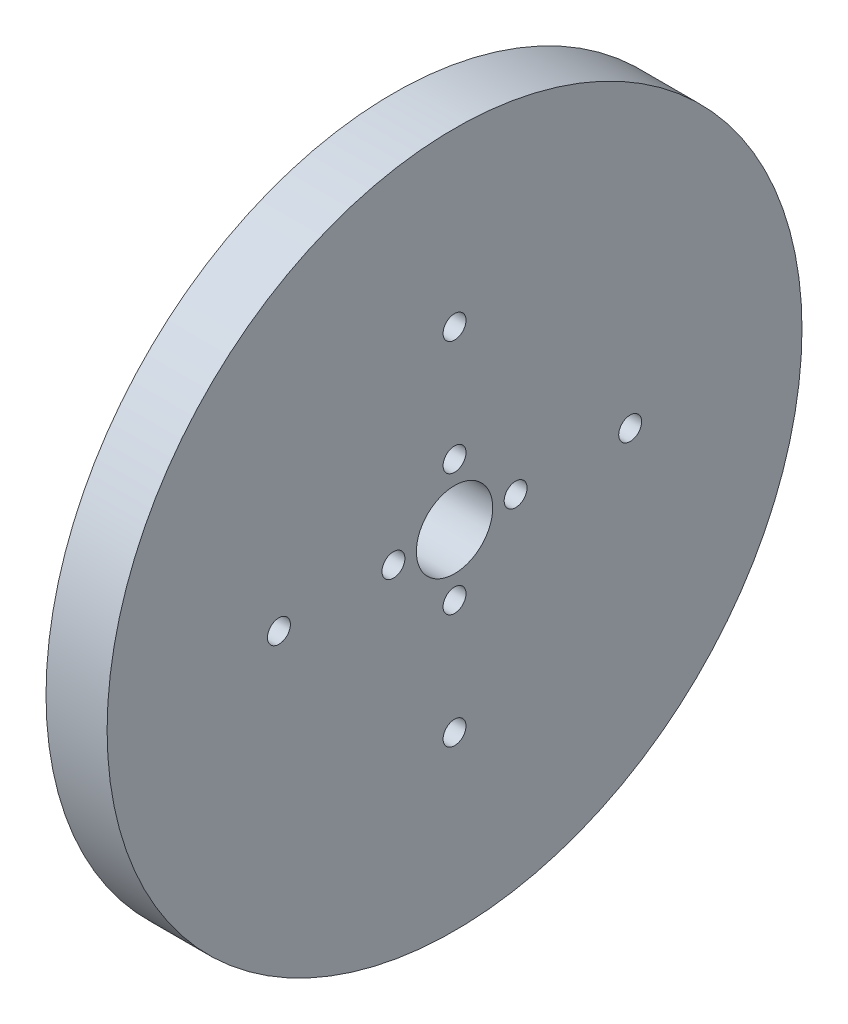
from build123d import *

# Parameters (mm, degrees)
SPROCKET_R                   = 45.5
ESTRUSIONE_ESTRUSIONE2_DEPTH = 8
SCHIZZO1_R                   = 5
SCHIZZO1_R_2                 = 1.5
TAGLIO_ESTRUSIONE2_DEPTH     = 9


with BuildPart() as part:
    # Sprocket → Estrusione-Estrusione2 (new body)
    with BuildSketch(Plane(origin=(0, 0, 0), x_dir=(0, 0, -1), z_dir=(1, 0, 0))):
        Circle(SPROCKET_R)
    extrude(amount=ESTRUSIONE_ESTRUSIONE2_DEPTH)

    # Schizzo1 → Taglio-Estrusione2 (cut, through all)
    with BuildSketch(Plane(origin=(0, 0, 0), x_dir=(0, 0, -1), z_dir=(1, 0, 0))):
        Circle(SCHIZZO1_R)
        with Locations((0, 23)):
            Circle(SCHIZZO1_R_2)
        with Locations((8, 0)):
            Circle(SCHIZZO1_R_2)
        with Locations((0, 8)):
            Circle(SCHIZZO1_R_2)
        with Locations((23, 0)):
            Circle(SCHIZZO1_R_2)
        with Locations((0, -8)):
            Circle(SCHIZZO1_R_2)
        with Locations((0, -23)):
            Circle(SCHIZZO1_R_2)
        with Locations((-8, 0)):
            Circle(SCHIZZO1_R_2)
        with Locations((-23, 0)):
            Circle(SCHIZZO1_R_2)
    extrude(amount=TAGLIO_ESTRUSIONE2_DEPTH, mode=Mode.SUBTRACT)


solid = part.part
